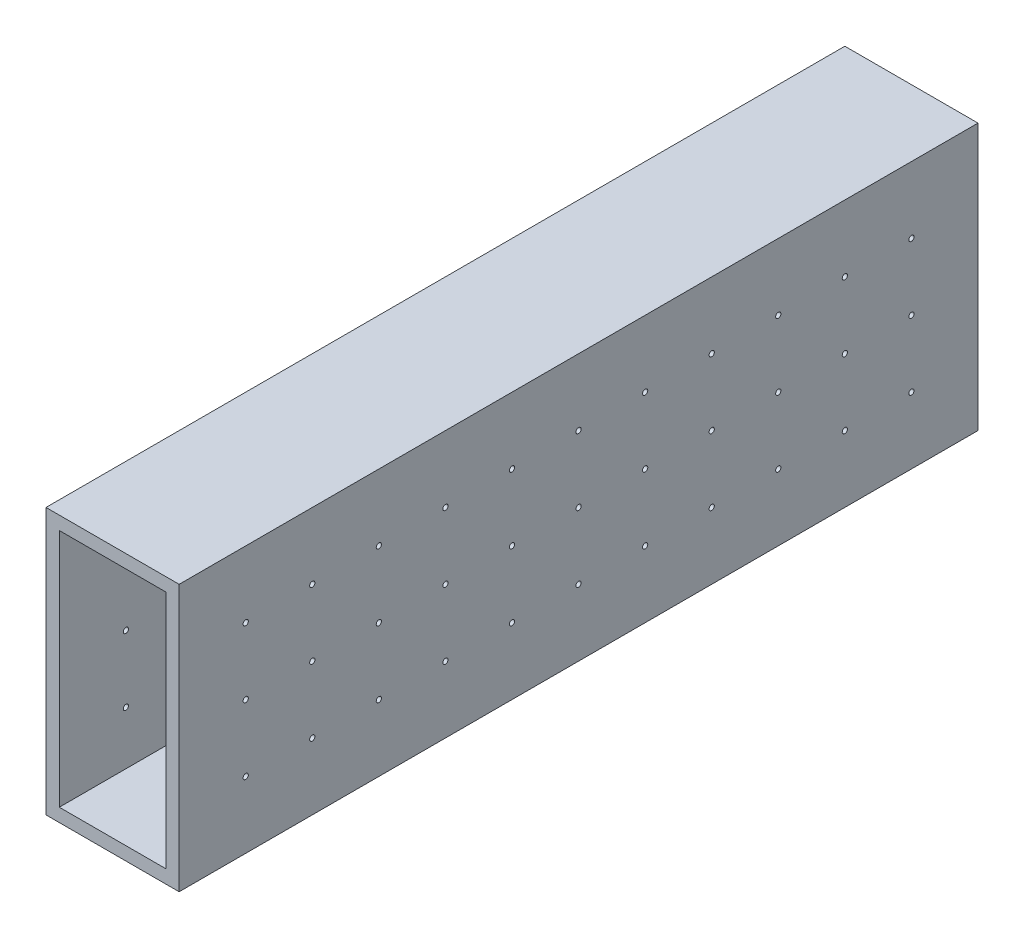
from build123d import *

# Parameters (mm, degrees)
SKETCH1_W               = 25.4
SKETCH1_H               = 50.8
SKETCH1_W_2             = 20.32
SKETCH1_H_2             = 45.72
BOSS_EXTRUDE1_DEPTH     = 152.4
SKETCH2_R               = 0.5
CUT_EXTRUDE1_DEPTH      = 1
CUT_EXTRUDE1_DEPTH_BACK = 26.4


with BuildPart() as part:
    # Sketch1 → Boss-Extrude1 (new body)
    with BuildSketch(Plane.XY):
        with Locations((19.67254902, 22.478169935)):
            Rectangle(SKETCH1_W, SKETCH1_H)
        with Locations((19.67254902, 22.478169935)):
            Rectangle(SKETCH1_W_2, SKETCH1_H_2, mode=Mode.SUBTRACT)
    extrude(amount=BOSS_EXTRUDE1_DEPTH)

    # Sketch2 → Cut-Extrude1 (cut, two sides)
    with BuildSketch(Plane(origin=(32.37254902, 0, 0), x_dir=(0, 0, -1), z_dir=(1, 0, 0))) as cut_extrude1_sk:
        with Locations((-139.7, 35.178169935)):
            Circle(SKETCH2_R)
        with Locations((-127, 35.178169935)):
            Circle(SKETCH2_R)
        with Locations((-114.3, 35.178169935)):
            Circle(SKETCH2_R)
        with Locations((-101.6, 35.178169935)):
            Circle(SKETCH2_R)
        with Locations((-88.9, 35.178169935)):
            Circle(SKETCH2_R)
        with Locations((-76.2, 35.178169935)):
            Circle(SKETCH2_R)
        with Locations((-63.5, 35.178169935)):
            Circle(SKETCH2_R)
        with Locations((-50.8, 35.178169935)):
            Circle(SKETCH2_R)
        with Locations((-38.1, 35.178169935)):
            Circle(SKETCH2_R)
        with Locations((-25.4, 35.178169935)):
            Circle(SKETCH2_R)
        with Locations((-12.7, 35.178169935)):
            Circle(SKETCH2_R)
        with Locations((-127, 22.478169935)):
            Circle(SKETCH2_R)
        with Locations((-114.3, 22.478169935)):
            Circle(SKETCH2_R)
        with Locations((-101.6, 22.478169935)):
            Circle(SKETCH2_R)
        with Locations((-88.9, 22.478169935)):
            Circle(SKETCH2_R)
        with Locations((-76.2, 22.478169935)):
            Circle(SKETCH2_R)
        with Locations((-63.5, 22.478169935)):
            Circle(SKETCH2_R)
        with Locations((-50.8, 22.478169935)):
            Circle(SKETCH2_R)
        with Locations((-38.1, 22.478169935)):
            Circle(SKETCH2_R)
        with Locations((-25.4, 22.478169935)):
            Circle(SKETCH2_R)
        with Locations((-12.7, 22.478169935)):
            Circle(SKETCH2_R)
        with Locations((-127, 9.778169935)):
            Circle(SKETCH2_R)
        with Locations((-114.3, 9.778169935)):
            Circle(SKETCH2_R)
        with Locations((-101.6, 9.778169935)):
            Circle(SKETCH2_R)
        with Locations((-88.9, 9.778169935)):
            Circle(SKETCH2_R)
        with Locations((-76.2, 9.778169935)):
            Circle(SKETCH2_R)
        with Locations((-63.5, 9.778169935)):
            Circle(SKETCH2_R)
        with Locations((-50.8, 9.778169935)):
            Circle(SKETCH2_R)
        with Locations((-38.1, 9.778169935)):
            Circle(SKETCH2_R)
        with Locations((-25.4, 9.778169935)):
            Circle(SKETCH2_R)
        with Locations((-12.7, 9.778169935)):
            Circle(SKETCH2_R)
        with Locations((-139.7, 22.478169935)):
            Circle(SKETCH2_R)
        with Locations((-139.7, 9.778169935)):
            Circle(SKETCH2_R)
    extrude(amount=CUT_EXTRUDE1_DEPTH, mode=Mode.SUBTRACT)
    extrude(cut_extrude1_sk.sketch, amount=-CUT_EXTRUDE1_DEPTH_BACK, mode=Mode.SUBTRACT)


solid = part.part
